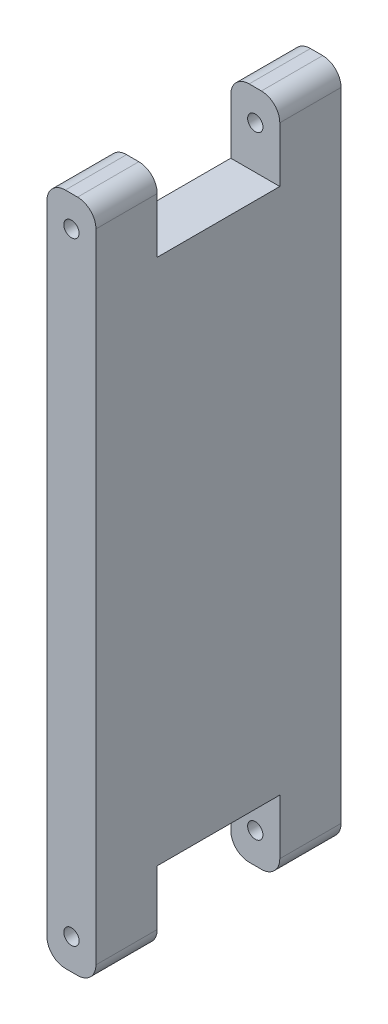
from build123d import *

# Parameters (mm, degrees)
SKETCH1_W           = 8
SKETCH1_H           = 110
BOSS_EXTRUDE1_DEPTH = 40
SKETCH2_W           = 20
SKETCH2_H           = 24
CUT_EXTRUDE1_DEPTH  = 9
FILLET1_R           = 3
SKETCH3_R           = 1.25
CUT_EXTRUDE2_DEPTH  = 41


with BuildPart() as part:
    # Sketch1 → Boss-Extrude1 (new body)
    with BuildSketch(Plane.XY):
        Rectangle(SKETCH1_W, SKETCH1_H)
    extrude(amount=-BOSS_EXTRUDE1_DEPTH)

    # Sketch2 → Cut-Extrude1 (cut, through all)
    with BuildSketch(Plane(origin=(4, 0, 0), x_dir=(0, 0, -1), z_dir=(1, 0, 0))):
        with Locations((20, 55)):
            Rectangle(SKETCH2_W, SKETCH2_H)
        with Locations((20, -55)):
            Rectangle(SKETCH2_W, SKETCH2_H)
    extrude(amount=-CUT_EXTRUDE1_DEPTH, mode=Mode.SUBTRACT)

    # Fillet1
    fillet1_edges = [part.edges().sort_by_distance(p)[0] for p in [
        (4, 55, -5),
        (-4, 55, -5),
        (-4, -55, -5),
        (4, -55, -5),
        (4, -55, -35),
        (-4, -55, -35),
        (-4, 55, -35),
        (4, 55, -35),
    ]]
    fillet(fillet1_edges, radius=FILLET1_R)

    # Sketch3 → Cut-Extrude2 (cut, through all)
    with BuildSketch(Plane.XY):
        with Locations((0, 50)):
            Circle(SKETCH3_R)
        with Locations((0, -50)):
            Circle(SKETCH3_R)
    extrude(amount=-CUT_EXTRUDE2_DEPTH, mode=Mode.SUBTRACT)


solid = part.part
